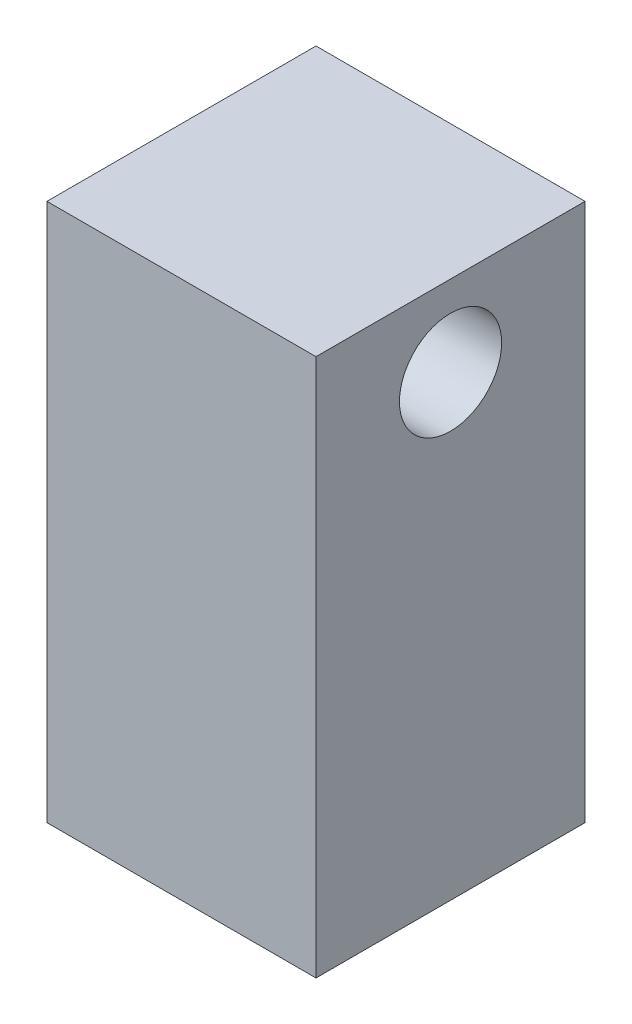
from build123d import *

# Parameters (mm, degrees)
SKETCH1_W                 = 10
SKETCH1_H                 = 10
BOSS_EXTRUDE1_DEPTH       = 20
F_6_CLEARANCE_HOLE1_D     = 3.7973
F_6_CLEARANCE_HOLE1_DEPTH = 17
F_6_CLEARANCE_HOLE1_TIP   = 1.140824014
SKETCH2_W                 = 7
SKETCH2_H                 = 7
CUT_EXTRUDE1_DEPTH        = 7


with BuildPart() as part:
    # Sketch1 → Boss-Extrude1 (new body)
    with BuildSketch(Plane(origin=(0, 0, 0), x_dir=(1, 0, 0), z_dir=(0, 1, 0))):
        with Locations((9.826837964, -46.174693154)):
            Rectangle(SKETCH1_W, SKETCH1_H)
    extrude(amount=-BOSS_EXTRUDE1_DEPTH)

    # #6 Clearance Hole1
    with Locations(Plane(origin=(4.826837964, -3, 46.174693154), x_dir=(0, 0, -1), z_dir=(-1, 0, 0))):
        with Locations((0, 0)):
            Hole(F_6_CLEARANCE_HOLE1_D / 2, depth=F_6_CLEARANCE_HOLE1_DEPTH)
            with Locations((0, 0, -(F_6_CLEARANCE_HOLE1_DEPTH + F_6_CLEARANCE_HOLE1_TIP / 2))):  # 118° drill point
                Cone(0, F_6_CLEARANCE_HOLE1_D / 2, F_6_CLEARANCE_HOLE1_TIP, mode=Mode.SUBTRACT)

    # Sketch2 → Cut-Extrude1 (cut)
    with BuildSketch(Plane.ZY.offset(-4.826837964)):
        with Locations((46.174693154, -14.5)):
            Rectangle(SKETCH2_W, SKETCH2_H)
    extrude(amount=-CUT_EXTRUDE1_DEPTH, mode=Mode.SUBTRACT)


solid = part.part
